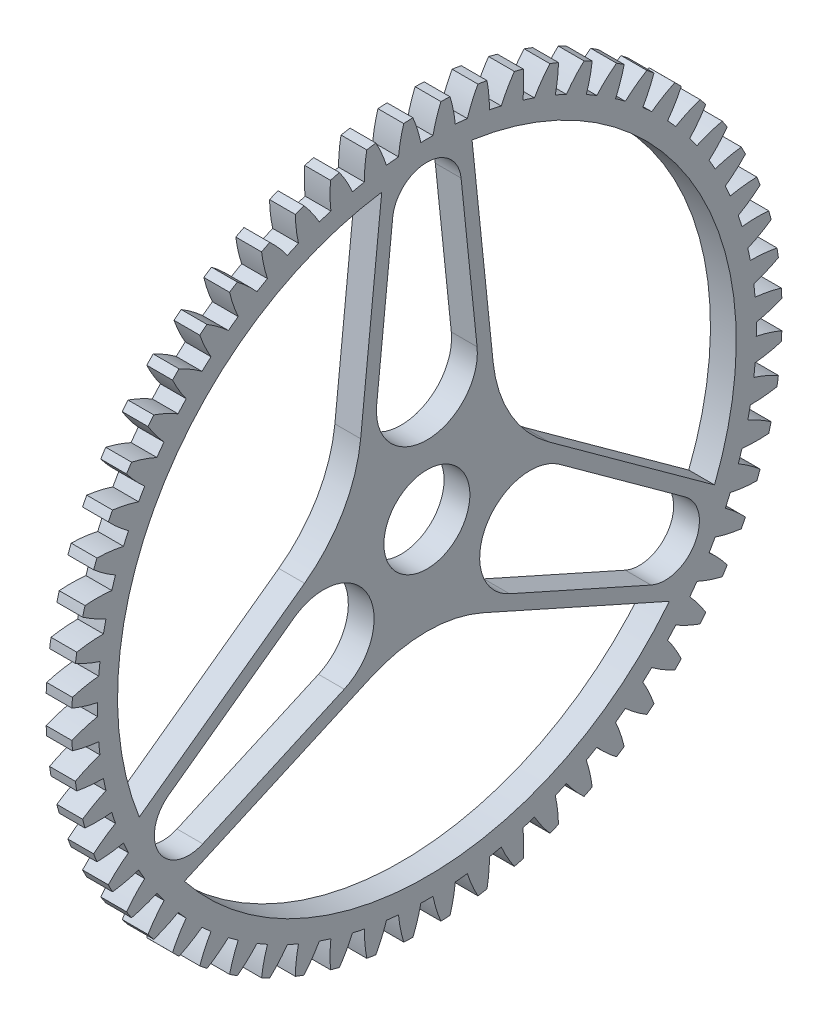
from build123d import *

# Parameters (mm, degrees)
BASPROSKE_W        = 4.7625
BASPROSKE_H        = 65.616666667
TOOTHCUT_DEPTH     = 93.918110695
TEETHCUTS_COUNT    = 60
TEETHCUTS_ANGLE    = 354
BORSKE_R           = 7.9375
BORE_DEPTH         = 50.8000508
CUT_EXTRUDE7_DEPTH = 93.846121625
FILLET1_R          = 25.4


with BuildPart() as part:
    # BasProSke → Base-Revolve (revolve)
    with BuildSketch(Plane(origin=(0, 0, 0), x_dir=(1, 0, 0), z_dir=(0, 1, 0)), mode=Mode.PRIVATE) as base_revolve_sk:
        with Locations((2.38125, 32.808333334)):
            Rectangle(BASPROSKE_W, BASPROSKE_H)
    revolve(base_revolve_sk.sketch.rotate(Axis((-10, 0, 0), (1, 0, 0)), 180), axis=Axis((-10, 0, 0), (1, 0, 0)))

    # TooCutSke → ToothCut (cut, through all)
    with BuildSketch(Plane(origin=(0, 0, 0), x_dir=(0, 0, -1), z_dir=(1, 0, 0))):
        with BuildLine():
            ThreePointArc((1.119877708, 60.842591222), (0, 60.852896667), (-1.119877708, 60.842591222))
            ThreePointArc((-1.119877708, 60.842591222), (-1.741655107, 63.252862303), (-2.596367657, 65.590698969))
            ThreePointArc((-2.596367657, 65.590698969), (0, 65.642066667), (2.596367657, 65.590698969))
            ThreePointArc((2.596367657, 65.590698969), (1.741655107, 63.252862303), (1.119877708, 60.842591222))
        make_face()
    toothcut = extrude(amount=TOOTHCUT_DEPTH, mode=Mode.SUBTRACT)

    # TeethCuts: ToothCut ×60 about axis
    teethcuts_axis = Axis((-10, 0, 0), (1, 0, 0))
    for i in range(1, TEETHCUTS_COUNT):
        add(toothcut.rotate(teethcuts_axis, i * TEETHCUTS_ANGLE / (TEETHCUTS_COUNT - 1)), mode=Mode.SUBTRACT)

    # BorSke → Bore (cut, symmetric)
    with BuildSketch(Plane(origin=(0, 0, 0), x_dir=(0, 0, -1), z_dir=(1, 0, 0))):
        with Locations(Location((0, 0, 0), (0, 0, 180))):
            Circle(BORSKE_R)
    extrude(amount=BORE_DEPTH, both=True, mode=Mode.SUBTRACT)

    # Sketch1 → Cut-Extrude7 (cut, through all)
    with BuildSketch(Plane(origin=(4.7625, 0, 0), x_dir=(0, 0, -1), z_dir=(1, 0, 0))):
        with BuildLine():
            Line((-6.316058005, 51.455676196), (-9.271724788, 22.984057173))
            ThreePointArc((-9.271724788, 22.984057173), (0, 12.7), (9.271724788, 22.984057173))
            Line((9.271724788, 22.984057173), (6.316058005, 51.455676196))
            ThreePointArc((6.316058005, 51.455676196), (0, 57.15), (-6.316058005, 51.455676196))
        make_face()
        with BuildLine():
            ThreePointArc((-15.268915, -19.52157779), (-10.998522628, -6.35), (-24.540639788, -3.462479384))
            Line((-24.540639788, -3.462479384), (-47.719951757, -20.257971413))
            ThreePointArc((-47.719951757, -20.257971413), (-49.493351826, -28.575), (-41.403893752, -31.197704782))
            Line((-41.403893752, -31.197704782), (-15.268915, -19.52157779))
        make_face()
        with BuildLine():
            Line((47.719951757, -20.257971413), (24.540639788, -3.462479384))
            ThreePointArc((24.540639788, -3.462479384), (10.998522628, -6.35), (15.268915, -19.52157779))
            Line((15.268915, -19.52157779), (41.403893752, -31.197704782))
            ThreePointArc((41.403893752, -31.197704782), (49.493351826, -28.575), (47.719951757, -20.257971413))
        make_face()
        with BuildLine():
            Line((-53.134297555, -21.044451128), (-13.40777323, 7.740981484))
            Line((-13.40777323, 7.740981484), (-8.342119492, 56.537877059))
            ThreePointArc((-8.342119492, 56.537877059), (-49.493351826, 28.575), (-53.134297555, -21.044451128))
        make_face()
        with BuildLine():
            Line((8.342119492, 56.537877059), (13.40777323, 7.740981484))
            Line((13.40777323, 7.740981484), (53.134297555, -21.044451128))
            ThreePointArc((53.134297555, -21.044451128), (49.493351826, 28.575), (8.342119492, 56.537877059))
        make_face()
        with BuildLine():
            Line((44.792178063, -35.493425931), (0, -15.481962967))
            Line((0, -15.481962967), (-44.792178063, -35.493425931))
            ThreePointArc((-44.792178063, -35.493425931), (0, -57.15), (44.792178063, -35.493425931))
        make_face()
    extrude(amount=-CUT_EXTRUDE7_DEPTH, mode=Mode.SUBTRACT)

    # Fillet1
    fillet1_edges = [part.edges().sort_by_distance(p)[0] for p in [
        (2.38125, 7.740981484, 13.40777323),
        (2.38125, 7.740981484, -13.40777323),
        (2.38125, -15.481962967, 0),
    ]]
    fillet(fillet1_edges, radius=FILLET1_R)


solid = part.part
